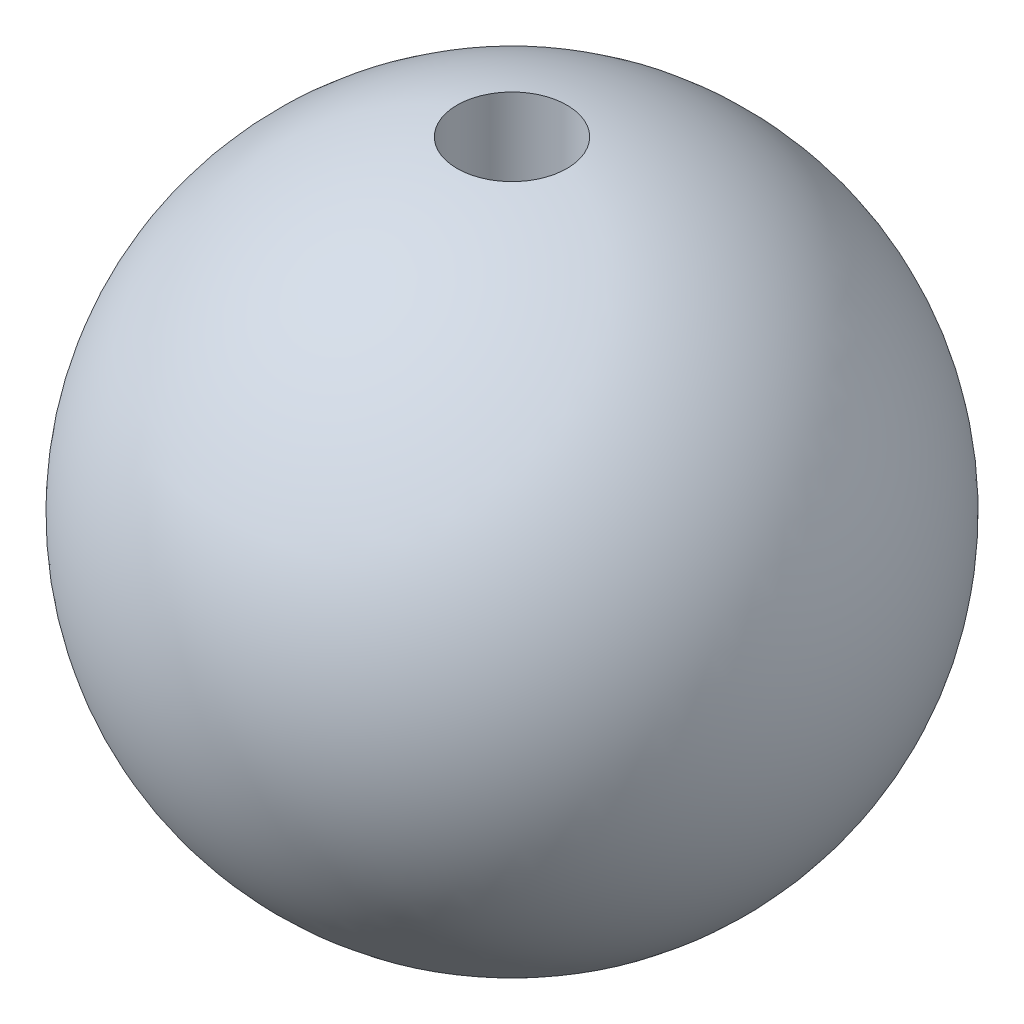
from build123d import *


with BuildPart() as part:
    # 草图1 → 旋转4 (revolve)
    with BuildSketch(Plane.XY):
        with BuildLine():
            Line((-5, 29.580398915), (-5, 0))
            Line((-5, 0), (0, 0))
            Line((0, 0), (0, -30))
            ThreePointArc((0, -30), (-29.894915684, -2.508787808), (-5, 29.580398915))
        make_face()
    revolve(axis=Axis((0, 30, 0), (0, -1, 0)))


solid = part.part
